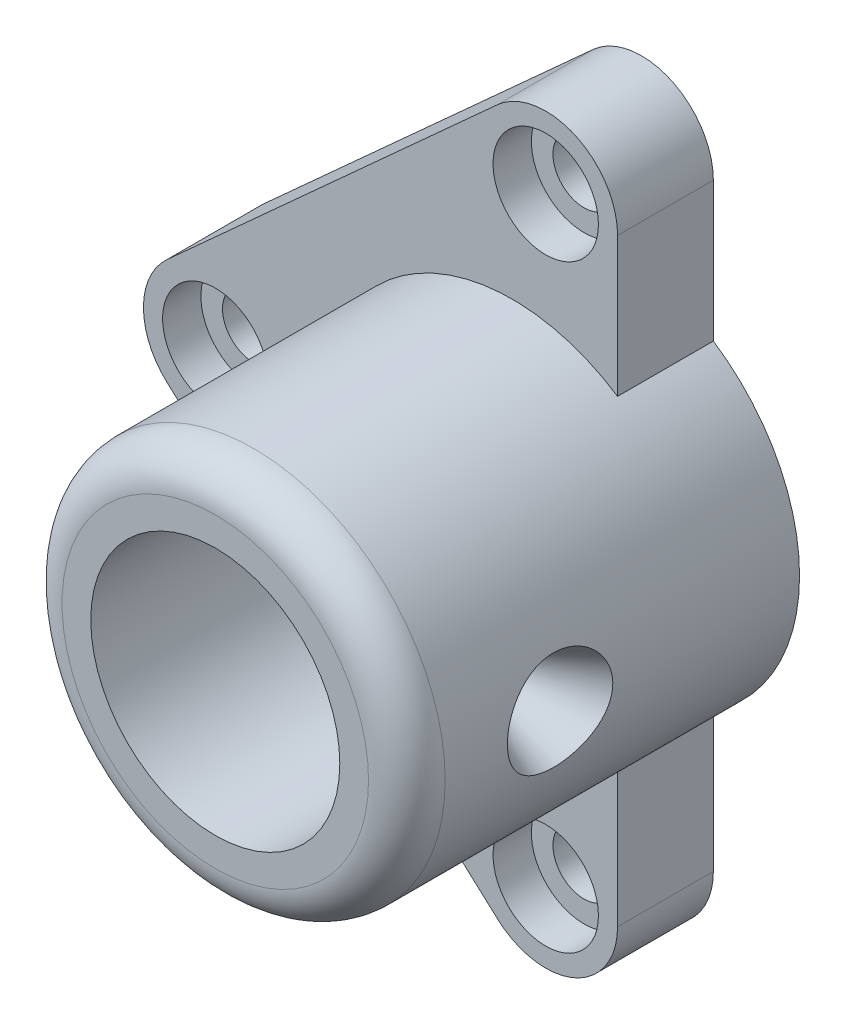
from build123d import *

# Parameters (mm, degrees)
SKETCH1_R                                         = 40
SKETCH1_R_2                                       = 26
BOSS_EXTRUDE1_DEPTH                               = 82
BOSS_EXTRUDE2_DEPTH                               = 20
SKETCH4_R                                         = 26
CUT_EXTRUDE1_DEPTH                                = 22
CBORE_FOR_M10_HEX_HEAD_BOLT2_D                    = 13
CBORE_FOR_M10_HEX_HEAD_BOLT2_CBORE_D              = 22
CBORE_FOR_M10_HEX_HEAD_BOLT2_CBORE_DEPTH          = 8
FILLET1_R                                         = 8
CSK_FOR_M10_FLAT_HEAD_MACHINE_SCREW12_D           = 10
CSK_FOR_M10_FLAT_HEAD_MACHINE_SCREW12_DEPTH       = 30
CSK_FOR_M10_FLAT_HEAD_MACHINE_SCREW12_CSINK_D     = 22
CSK_FOR_M10_FLAT_HEAD_MACHINE_SCREW12_CSINK_ANGLE = 50
CSK_FOR_M10_FLAT_HEAD_MACHINE_SCREW12_TIP         = 3.004303095
SKETCH22_R                                        = 30
CUT_EXTRUDE2_DEPTH                                = 6


with BuildPart() as part:
    # Sketch1 → Boss-Extrude1 (new body)
    with BuildSketch(Plane(origin=(0, 0, 0), x_dir=(0, 1, 0), z_dir=(0, 0, 1))):
        with Locations(Location((0, 0, 0), (0, 0, 270))):
            Circle(SKETCH1_R)
        with Locations(Location((0, 0, 0), (0, 0, 270))):
            Circle(SKETCH1_R_2, mode=Mode.SUBTRACT)
    extrude(amount=BOSS_EXTRUDE1_DEPTH)

    # Sketch2 → Boss-Extrude2 (add)
    with BuildSketch(Plane(origin=(0, 0, 0), x_dir=(0, 1, 0), z_dir=(0, 0, 1))):
        with BuildLine():
            Line((-73.617309286, 3.070026527), (-11.117309286, 72.070026527))
            ThreePointArc((-11.117309286, 72.070026527), (0, 77), (11.117309286, 72.070026527))
            Line((11.117309286, 72.070026527), (73.617309286, 3.070026527))
            ThreePointArc((73.617309286, 3.070026527), (76.212228081, -13.080690837), (62.5, -22))
            Line((62.5, -22), (33.406586177, -22))
            ThreePointArc((33.406586177, -22), (0, -40), (-33.406586177, -22))
            Line((-33.406586177, -22), (-62.5, -22))
            ThreePointArc((-62.5, -22), (-76.212228081, -13.080690837), (-73.617309286, 3.070026527))
        make_face()
    extrude(amount=BOSS_EXTRUDE2_DEPTH)

    # Sketch4 → Cut-Extrude1 (cut)
    with BuildSketch(Plane.XY.offset(20)):
        Circle(SKETCH4_R)
    extrude(amount=-CUT_EXTRUDE1_DEPTH, mode=Mode.SUBTRACT)

    # CBORE for M10 Hex Head Bolt2 (through all)
    with Locations(Plane(origin=(-62, 0, 20), x_dir=(1, 0, 0), z_dir=(0, 0, 1))):
        with Locations((0, 0), (69, 62.5), (69, -62.5)):
            CounterBoreHole(CBORE_FOR_M10_HEX_HEAD_BOLT2_D / 2, CBORE_FOR_M10_HEX_HEAD_BOLT2_CBORE_D / 2, CBORE_FOR_M10_HEX_HEAD_BOLT2_CBORE_DEPTH)

    # Fillet1
    fillet1_edges = [part.edges().sort_by_distance(p)[0] for p in [
        (-40, 0, 82),
    ]]
    fillet(fillet1_edges, radius=FILLET1_R)

    # CSK for M10 Flat Head Machine Screw12
    with Locations(Plane.YZ.offset(40)):
        with Locations((0, 50)):
            CounterSinkHole(CSK_FOR_M10_FLAT_HEAD_MACHINE_SCREW12_D / 2, CSK_FOR_M10_FLAT_HEAD_MACHINE_SCREW12_CSINK_D / 2, depth=CSK_FOR_M10_FLAT_HEAD_MACHINE_SCREW12_DEPTH, counter_sink_angle=CSK_FOR_M10_FLAT_HEAD_MACHINE_SCREW12_CSINK_ANGLE)
            with Locations((0, 0, -(CSK_FOR_M10_FLAT_HEAD_MACHINE_SCREW12_DEPTH + CSK_FOR_M10_FLAT_HEAD_MACHINE_SCREW12_TIP / 2))):  # 118° drill point
                Cone(0, CSK_FOR_M10_FLAT_HEAD_MACHINE_SCREW12_D / 2, CSK_FOR_M10_FLAT_HEAD_MACHINE_SCREW12_TIP, mode=Mode.SUBTRACT)

    # Sketch22 → Cut-Extrude2 (cut)
    with BuildSketch(Plane(origin=(0, 0, 0), x_dir=(1, 0, 0), z_dir=(0, 0, -1))):
        with Locations(Location((0, 0, 0), (0, 0, 180))):
            Circle(SKETCH22_R)
    extrude(amount=-CUT_EXTRUDE2_DEPTH, mode=Mode.SUBTRACT)


solid = part.part
